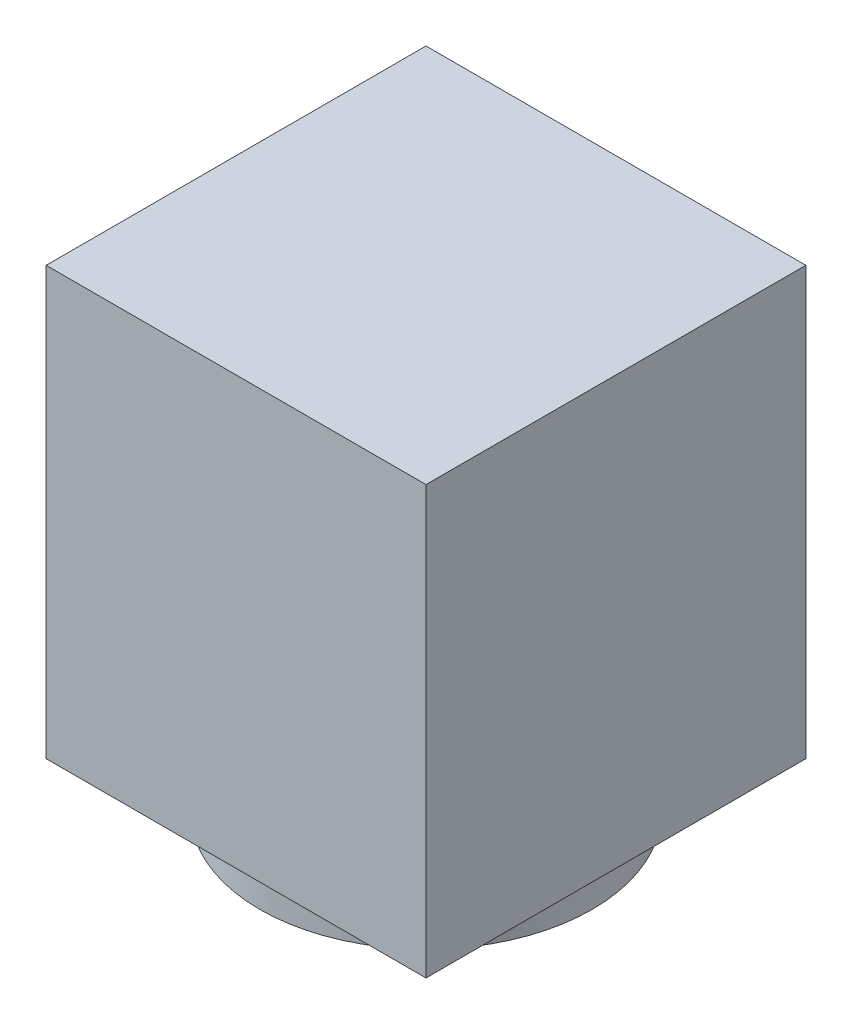
from build123d import *

# Parameters (mm, degrees)
SKETCH_1_R      = 7
EXTRUDE_1_DEPTH = 2
SKETCH_2_W      = 16
SKETCH_2_H      = 16
EXTRUDE_2_DEPTH = 18


with BuildPart() as part:
    # 草图1 → 凸台-拉伸1 (new body)
    with BuildSketch(Plane(origin=(0, 0, 0), x_dir=(1, 0, 0), z_dir=(0, 1, 0))):
        Circle(SKETCH_1_R)
    extrude(amount=EXTRUDE_1_DEPTH)

    # 草图2 → 凸台-拉伸2 (add)
    with BuildSketch(Plane(origin=(0, 2, 0), x_dir=(1, 0, 0), z_dir=(0, 1, 0))):
        Rectangle(SKETCH_2_W, SKETCH_2_H)
    extrude(amount=EXTRUDE_2_DEPTH)


solid = part.part
